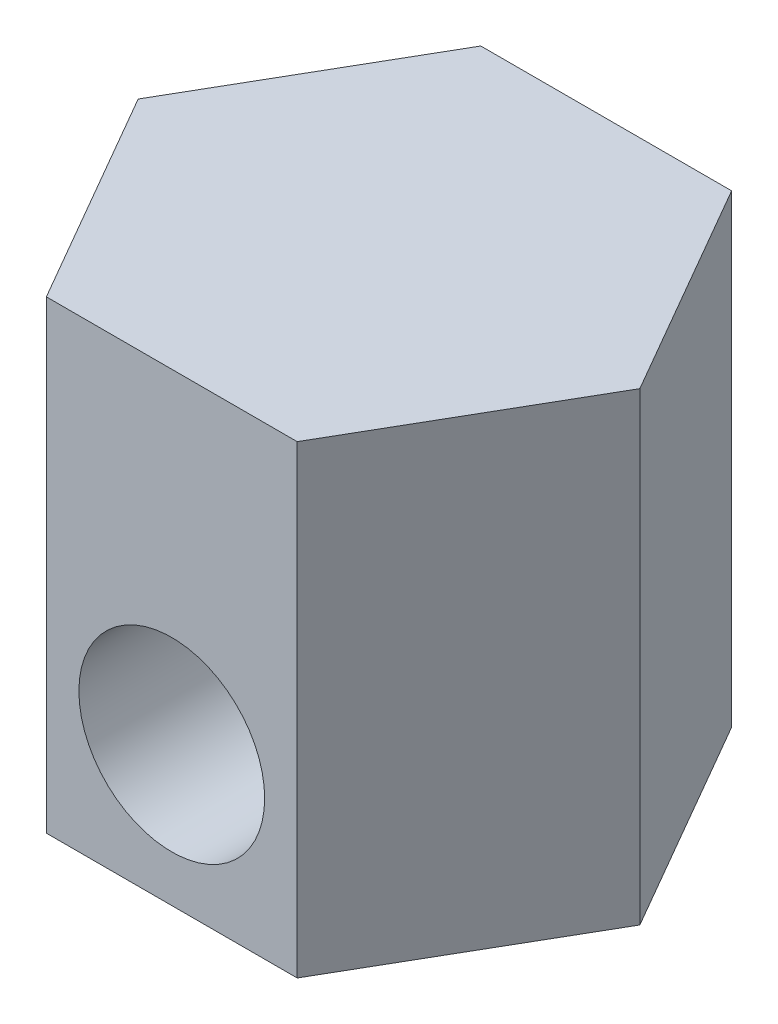
from build123d import *

# Parameters (mm, degrees)
SALIENTE_EXTRUIR1_DEPTH = 5
CROQUIS2_R              = 0.5
CORTAR_EXTRUIR1_DEPTH   = 5.67653718
CROQUIS3_R              = 1
CORTAR_EXTRUIR2_DEPTH   = 2


with BuildPart() as part:
    # Croquis1 → Saliente-Extruir1 (new body)
    with BuildSketch(Plane(origin=(0, 0, 0), x_dir=(1, 0, 0), z_dir=(0, 1, 0))):
        Polygon((2.7, 0), (1.35, 2.33826859), (-1.35, 2.33826859), (-2.7, 0), (-1.35, -2.33826859), (1.35, -2.33826859), align=None)
    extrude(amount=SALIENTE_EXTRUIR1_DEPTH)

    # Croquis2 → Cortar-Extruir1 (cut, through all)
    with BuildSketch(Plane.XY.offset(2.33826859)):
        with Locations((0, 1)):
            Circle(CROQUIS2_R)
    extrude(amount=-CORTAR_EXTRUIR1_DEPTH, mode=Mode.SUBTRACT)

    # Croquis3 → Cortar-Extruir2 (cut)
    with BuildSketch(Plane.XY.offset(2.33826859)):
        with Locations((0, 1.5)):
            Circle(CROQUIS3_R)
    extrude(amount=-CORTAR_EXTRUIR2_DEPTH, mode=Mode.SUBTRACT)


solid = part.part
